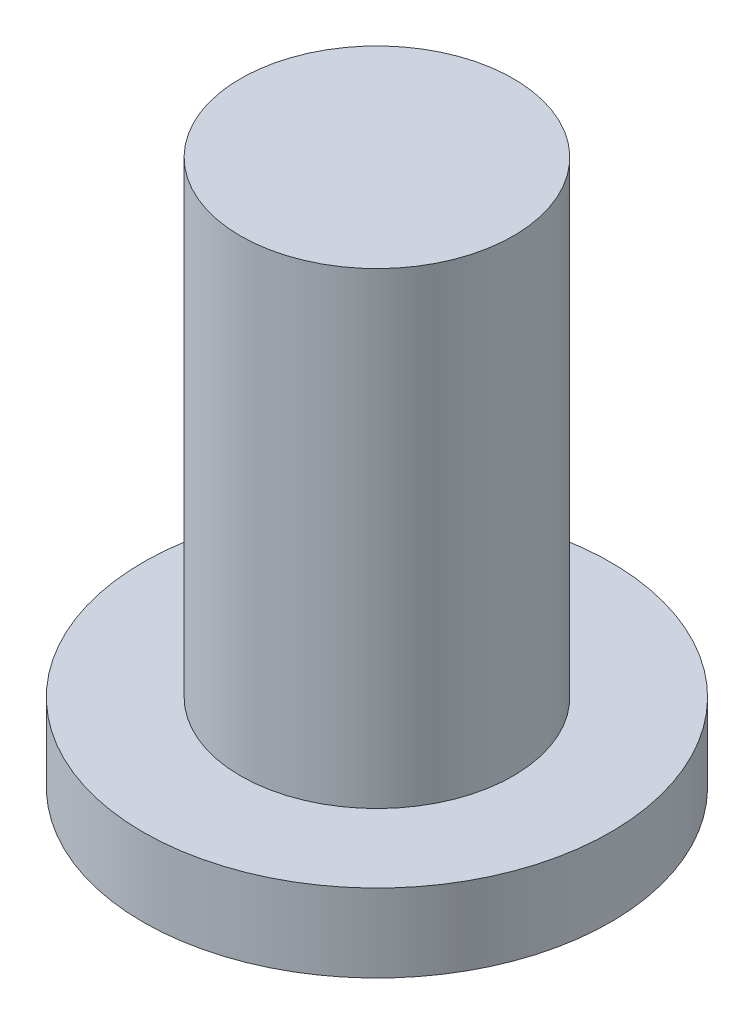
from build123d import *

# Parameters (mm, degrees)
CROQUIS1_R              = 6
SALIENTE_EXTRUIR1_DEPTH = 2
CROQUIS2_R              = 3.5
SALIENTE_EXTRUIR2_DEPTH = 12


with BuildPart() as part:
    # Croquis1 → Saliente-Extruir1 (new body)
    with BuildSketch(Plane(origin=(0, 0, 0), x_dir=(1, 0, 0), z_dir=(0, 1, 0))):
        Circle(CROQUIS1_R)
    extrude(amount=SALIENTE_EXTRUIR1_DEPTH)

    # Croquis2 → Saliente-Extruir2 (add)
    with BuildSketch(Plane(origin=(0, 2, 0), x_dir=(1, 0, 0), z_dir=(0, 1, 0))):
        Circle(CROQUIS2_R)
    extrude(amount=SALIENTE_EXTRUIR2_DEPTH)


solid = part.part
